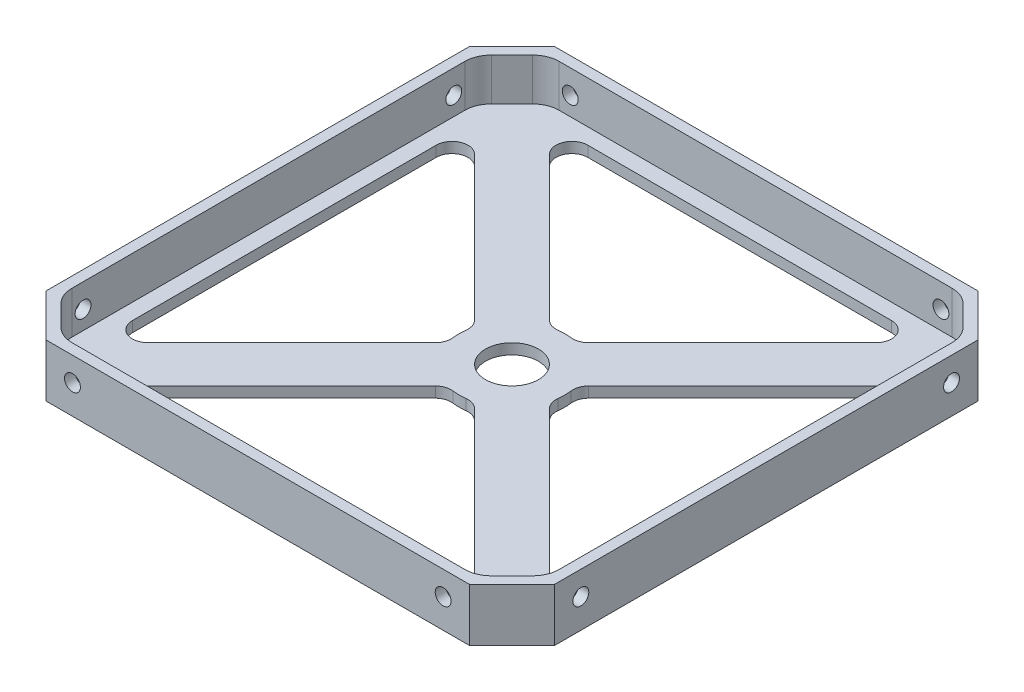
from build123d import *

# Parameters (mm, degrees)
BOSS_EXTRUDE1_DEPTH = 10
SHELL1_T            = -2
SKETCH2_R           = 5
CUT_EXTRUDE1_DEPTH  = 11
FILLET1_R           = 3
SKETCH3_R           = 1.5
CUT_EXTRUDE2_DEPTH  = 97
SKETCH4_R           = 1.5
CUT_EXTRUDE3_DEPTH  = 97
FILLET2_R           = 5


with BuildPart() as part:
    # Sketch1 → Boss-Extrude1 (new body)
    with BuildSketch(Plane(origin=(0, 0, 0), x_dir=(1, 0, 0), z_dir=(0, 1, 0))):
        Polygon((0, 88), (0, 8), (8, 0), (88, 0), (96, 8), (96, 88), (88, 96), (8, 96), align=None)
    extrude(amount=BOSS_EXTRUDE1_DEPTH)

    # Shell1
    shell1_openings = [part.faces().sort_by_distance(p)[0] for p in [
        (48, 10, -48),
    ]]
    offset(amount=SHELL1_T, openings=shell1_openings, kind=Kind.INTERSECTION)

    # Sketch2 → Cut-Extrude1 (cut, through all)
    with BuildSketch(Plane(origin=(0, 0, 0), x_dir=(-1, 0, 0), z_dir=(0, -1, 0))):
        with BuildLine():
            Line((-45.411809549, 57.659258263), (-12.071067812, 91))
            Line((-12.071067812, 91), (-83.928932188, 91))
            Line((-83.928932188, 91), (-50.588190451, 57.659258263))
            ThreePointArc((-50.588190451, 57.659258263), (-48, 58), (-45.411809549, 57.659258263))
        make_face()
        with BuildLine():
            Line((-5, 83.928932188), (-38.340741737, 50.588190451))
            ThreePointArc((-38.340741737, 50.588190451), (-38.085551386, 49.305261922), (-38, 48))
            ThreePointArc((-38, 48), (-38.085551386, 46.694738078), (-38.340741737, 45.411809549))
            Line((-38.340741737, 45.411809549), (-5, 12.071067812))
            Line((-5, 12.071067812), (-5, 83.928932188))
        make_face()
        with BuildLine():
            Line((-12.071067812, 5), (-45.411809549, 38.340741737))
            ThreePointArc((-45.411809549, 38.340741737), (-48, 38), (-50.588190451, 38.340741737))
            Line((-50.588190451, 38.340741737), (-83.928932188, 5))
            Line((-83.928932188, 5), (-12.071067812, 5))
        make_face()
        with BuildLine():
            ThreePointArc((-57.659258263, 45.411809549), (-58, 48), (-57.659258263, 50.588190451))
            Line((-57.659258263, 50.588190451), (-91, 83.928932188))
            Line((-91, 83.928932188), (-91, 12.071067812))
            Line((-91, 12.071067812), (-57.659258263, 45.411809549))
        make_face()
        with Locations((-48, 48)):
            Circle(SKETCH2_R)
    extrude(amount=-CUT_EXTRUDE1_DEPTH, mode=Mode.SUBTRACT)

    # Fillet1
    fillet1_edges = [part.edges().sort_by_distance(p)[0] for p in [
        (50.588190451, 1, -38.340741737),
        (45.411809549, 1, -38.340741737),
        (12.071067812, 1, -5),
        (83.928932188, 1, -5),
        (38.340741737, 1, -45.411809549),
        (38.340741737, 1, -50.588190451),
        (5, 1, -83.928932188),
        (5, 1, -12.071067812),
        (57.659258263, 1, -50.588190451),
        (57.659258263, 1, -45.411809549),
        (91, 1, -12.071067812),
        (91, 1, -83.928932188),
        (45.411809549, 1, -57.659258263),
        (50.588190451, 1, -57.659258263),
        (83.928932188, 1, -91),
        (12.071067812, 1, -91),
    ]]
    fillet(fillet1_edges, radius=FILLET1_R)

    # Sketch3 → Cut-Extrude2 (cut, through all)
    with BuildSketch(Plane(origin=(96, 0, 0), x_dir=(0, 0, -1), z_dir=(1, 0, 0))):
        with Locations((83, 5.5)):
            Circle(SKETCH3_R)
        with Locations((13, 5.5)):
            Circle(SKETCH3_R)
    extrude(amount=-CUT_EXTRUDE2_DEPTH, mode=Mode.SUBTRACT)

    # Sketch4 → Cut-Extrude3 (cut, through all)
    with BuildSketch(Plane.XY):
        with Locations((83, 5.5)):
            Circle(SKETCH4_R)
        with Locations((13, 5.5)):
            Circle(SKETCH4_R)
    extrude(amount=-CUT_EXTRUDE3_DEPTH, mode=Mode.SUBTRACT)

    # Fillet2
    fillet2_edges = [part.edges().sort_by_distance(p)[0] for p in [
        (8.828427125, 6, -94),
        (2, 6, -87.171572875),
        (2, 6, -8.828427125),
        (8.828427125, 6, -2),
        (87.171572875, 6, -2),
        (94, 6, -8.828427125),
        (94, 6, -87.171572875),
        (87.171572875, 6, -94),
    ]]
    fillet(fillet2_edges, radius=FILLET2_R)


solid = part.part
